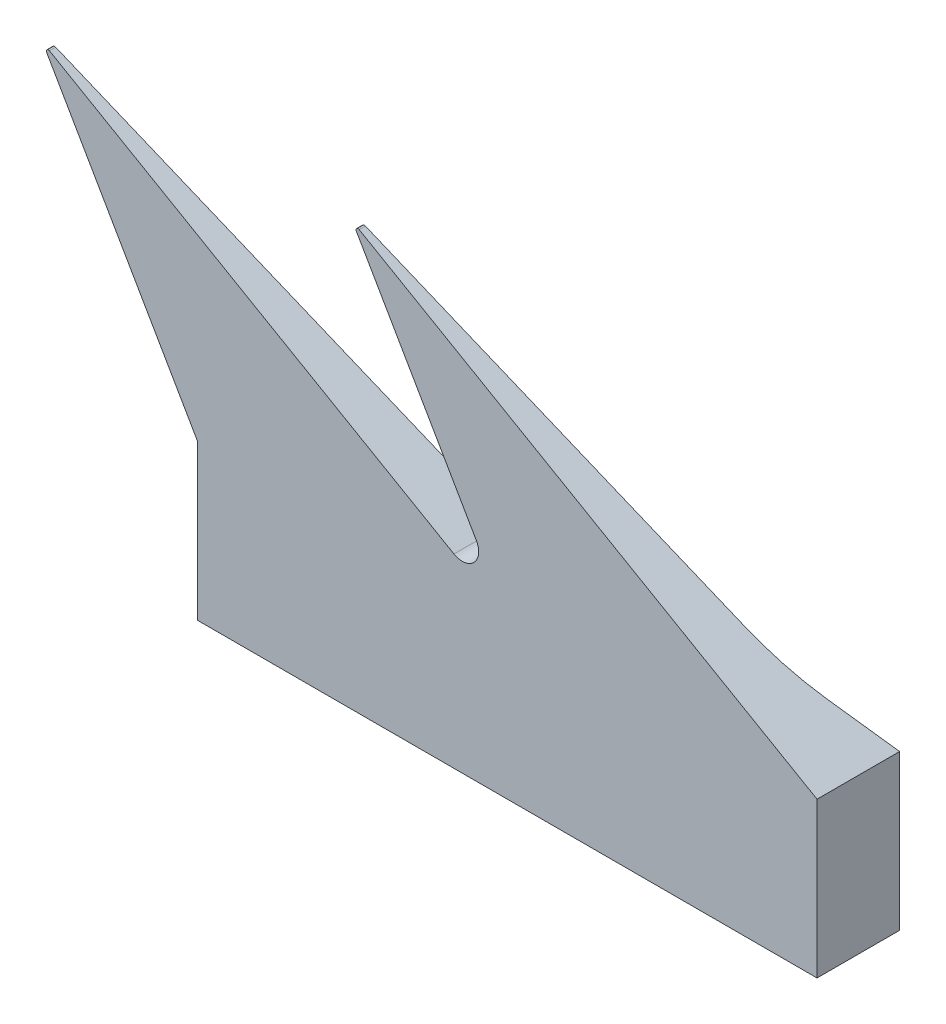
from build123d import *

# Parameters (mm, degrees)
SKETCH1_W           = 3
SKETCH1_H           = 0.75
BOSS_EXTRUDE2_DEPTH = 0.4
CUT_EXTRUDE2_DEPTH  = 7.4


with BuildPart() as part:
    # Sketch1 → Boss-Extrude2 (new body)
    with BuildSketch(Plane.XY):
        with Locations((0, -0.350910333)):
            Rectangle(SKETCH1_W, SKETCH1_H)
        with BuildLine():
            Line((1.5, 0.024089667), (-0.717679492, 1.304467518))
            ThreePointArc((-0.717679492, 1.304467518), (-0.72975056, 1.302878332), (-0.731339746, 1.290807264))
            Line((-0.731339746, 1.290807264), (-0.149282032, 0.282653731))
            ThreePointArc((-0.149282032, 0.282653731), (-0.161995522, 0.186085189), (-0.258564065, 0.173371699))
            Line((-0.258564065, 0.173371699), (-2.217679492, 1.304467518))
            ThreePointArc((-2.217679492, 1.304467518), (-2.22975056, 1.302878332), (-2.231339746, 1.290807264))
            Line((-2.231339746, 1.290807264), (-1.5, 0.024089667))
            Line((-1.5, 0.024089667), (1.5, 0.024089667))
        make_face()
    extrude(amount=BOSS_EXTRUDE2_DEPTH)

    # Sketch3 → Cut-Extrude2 (cut)
    with BuildSketch(Plane(origin=(1.5, 0, 0), x_dir=(0, 0, -1), z_dir=(1, 0, 0))):
        with BuildLine():
            Line((-0.395475089, 1.432117688), (-0.180277111, 0.356172496))
            ThreePointArc((-0.180277111, 0.356172496), (-0.150082623, 0.258498611), (-0.100652673, 0.16900797))
            Line((-0.100652673, 0.16900797), (0, 0.024089667))
            Line((0, 0.024089667), (0, 1.432117688))
            Line((0, 1.432117688), (-0.395475089, 1.432117688))
        make_face()
    extrude(amount=-CUT_EXTRUDE2_DEPTH, mode=Mode.SUBTRACT)


solid = part.part
